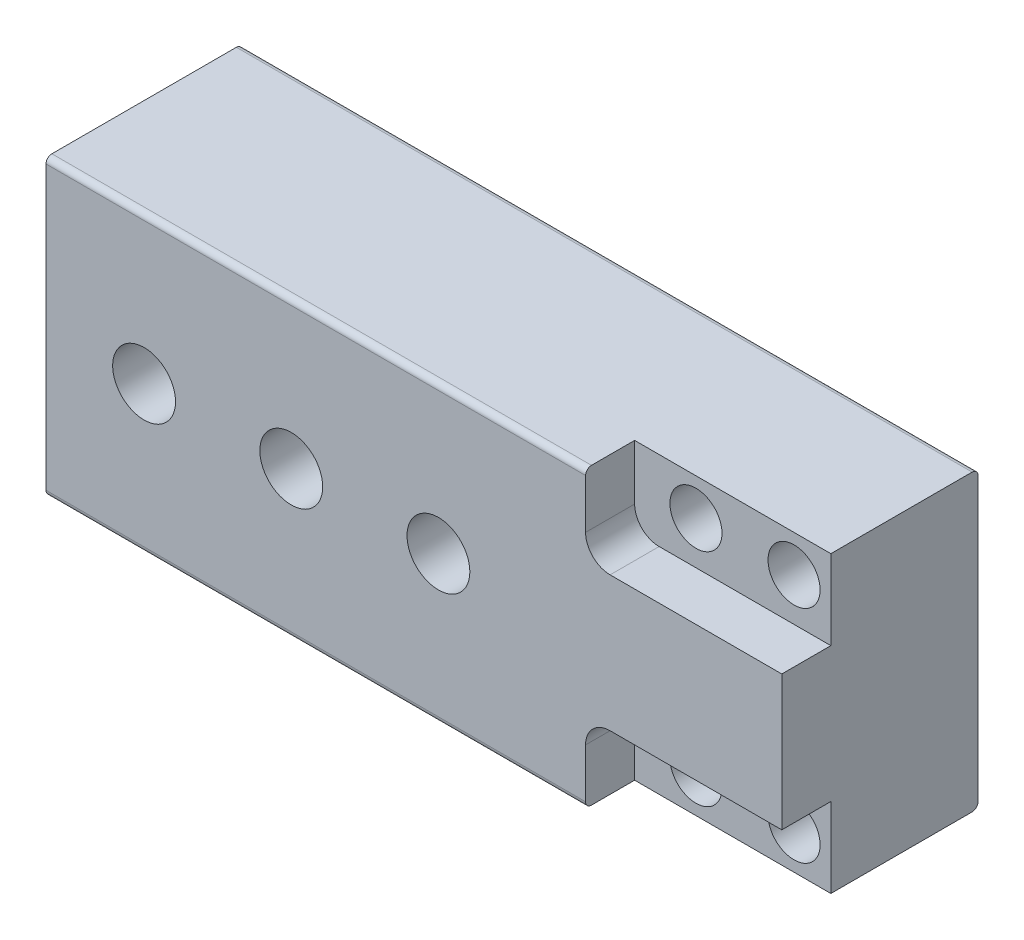
from build123d import *

# Parameters (mm, degrees)
SKETCH1_W                            = 190.5
SKETCH1_H                            = 76.2
BOSS_EXTRUDE1_DEPTH                  = 50.8
FILLET1_R                            = 1.524
F_41_64_0_64063_DIAMETER_HOLE1_D     = 16.272002
F_41_64_0_64063_DIAMETER_HOLE1_DEPTH = 26.162
F_1_2_0_5_DIAMETER_HOLE1_D           = 13.4874
CUT_EXTRUDE1_DEPTH                   = 12.7


with BuildPart() as part:
    # Sketch1 → Boss-Extrude1 (new body)
    with BuildSketch(Plane.XY):
        Rectangle(SKETCH1_W, SKETCH1_H)
    extrude(amount=BOSS_EXTRUDE1_DEPTH)

    # Fillet1
    fillet1_edges = [part.edges().sort_by_distance(p)[0] for p in [
        (0, 38.1, 50.8),
        (0, 38.1, 0),
        (0, -38.1, 0),
        (0, -38.1, 50.8),
    ]]
    fillet(fillet1_edges, radius=FILLET1_R)

    # 41/64 (0.64063) Diameter Hole1
    with Locations(Plane.XY.offset(50.8)):
        with Locations((-69.85, 0), (-31.75, 0), (6.35, 0)):
            Hole(F_41_64_0_64063_DIAMETER_HOLE1_D / 2, depth=F_41_64_0_64063_DIAMETER_HOLE1_DEPTH)

    # 1/2 (0.5) Diameter Hole1 (through all)
    with Locations(Plane.XY.offset(50.8)):
        with Locations((60.325, 28.575), (85.725, 28.575), (60.325, -28.575), (85.725, -28.575)):
            Hole(F_1_2_0_5_DIAMETER_HOLE1_D / 2)

    # Sketch7 → Cut-Extrude1 (cut)
    with BuildSketch(Plane.XY.offset(50.8)):
        with BuildLine():
            Line((95.25, 38.1), (44.45, 38.1))
            Line((44.45, 38.1), (44.45, 23.8252))
            ThreePointArc((44.45, 23.8252), (46.309871939, 19.335071939), (50.8, 17.4752))
            Line((50.8, 17.4752), (95.25, 17.4752))
            Line((95.25, 17.4752), (95.25, 38.1))
        make_face()
        with BuildLine():
            Line((50.8, -17.4752), (95.25, -17.4752))
            Line((95.25, -17.4752), (95.25, -38.1))
            Line((95.25, -38.1), (44.45, -38.1))
            Line((44.45, -38.1), (44.45, -23.8252))
            ThreePointArc((44.45, -23.8252), (46.309871939, -19.335071939), (50.8, -17.4752))
        make_face()
    extrude(amount=-CUT_EXTRUDE1_DEPTH, mode=Mode.SUBTRACT)


solid = part.part
